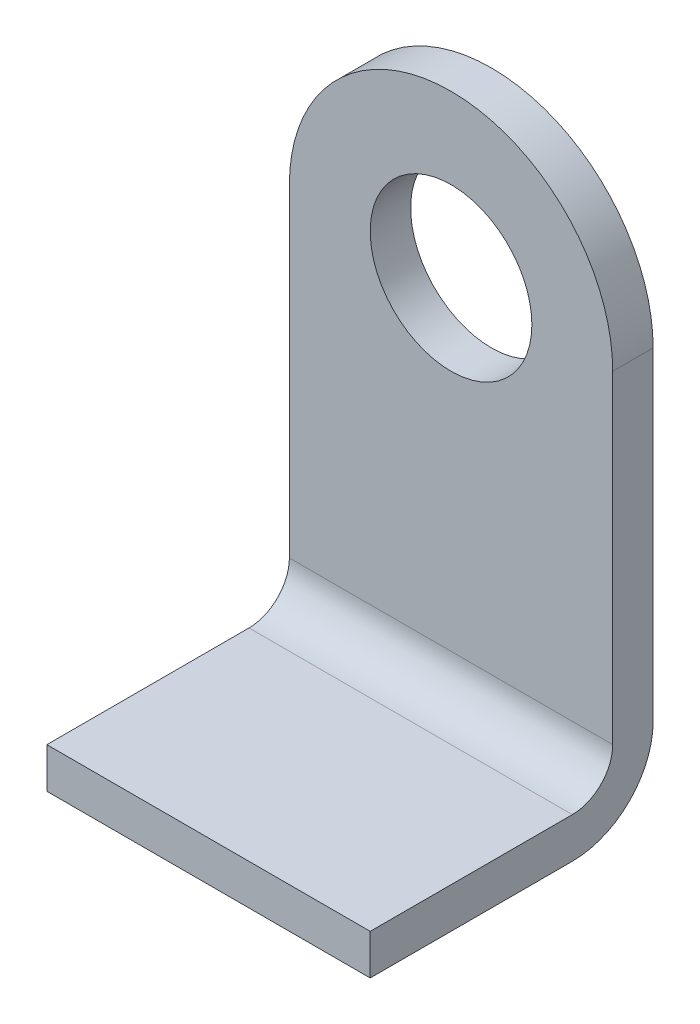
from build123d import *

# Parameters (mm, degrees)
EXTRUDE1_DEPTH      = 5
SKETCH2_R           = 10
CUT_EXTRUDE1_DEPTH  = 6
BOSS_EXTRUDE1_DEPTH = 40


with BuildPart() as part:
    # Sketch1 → Extrude1 (new body)
    with BuildSketch(Plane.XY):
        with BuildLine():
            Line((0, 40), (0, 0))
            Line((0, 0), (-40, 0))
            Line((-40, 0), (-40, 40))
            ThreePointArc((-40, 40), (-20, 60), (0, 40))
        make_face()
    extrude(amount=EXTRUDE1_DEPTH)

    # Sketch2 → Cut-Extrude1 (cut, through all)
    with BuildSketch(Plane.XY.offset(5)):
        with Locations((-20, 40)):
            Circle(SKETCH2_R)
    extrude(amount=-CUT_EXTRUDE1_DEPTH, mode=Mode.SUBTRACT)

    # Sketch3 → Boss-Extrude1 (add)
    with BuildSketch(Plane(origin=(0, 0, 0), x_dir=(0, 0, -1), z_dir=(1, 0, 0))):
        with BuildLine():
            Line((-10, -5), (-35, -5))
            Line((-35, -5), (-35, -10))
            Line((-35, -10), (-10, -10))
            ThreePointArc((-10, -10), (-2.928932188, -7.071067812), (0, 0))
            Line((0, 0), (-5, 0))
            ThreePointArc((-5, 0), (-6.464466094, -3.535533906), (-10, -5))
        make_face()
    extrude(amount=-BOSS_EXTRUDE1_DEPTH)


solid = part.part
